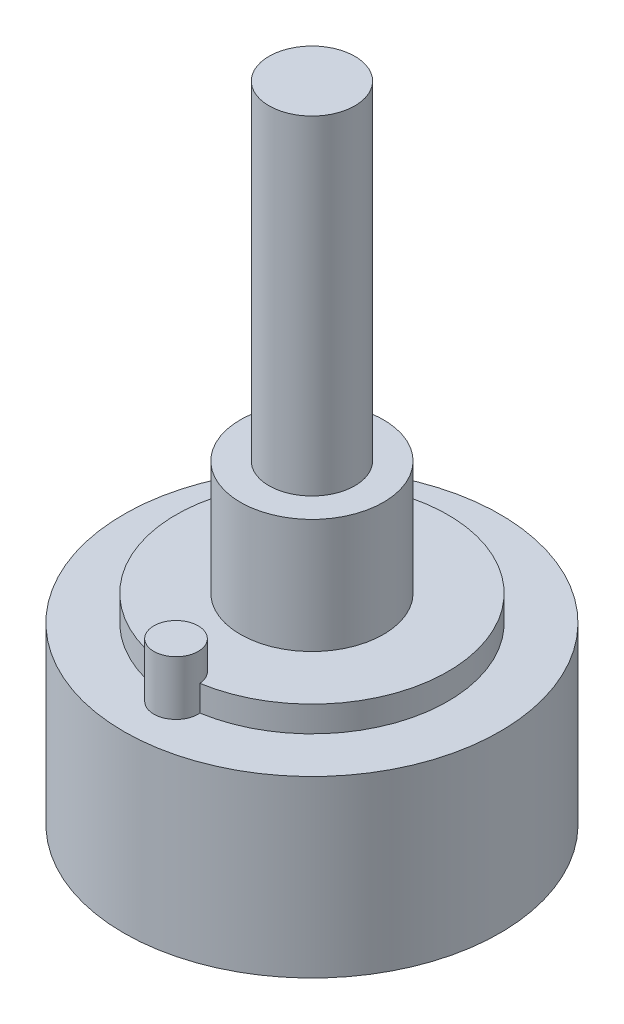
from build123d import *

# Parameters (mm, degrees)
SKETCH1_R           = 13.15
BOSS_EXTRUDE1_DEPTH = 12.2
SKETCH2_R           = 9.5
BOSS_EXTRUDE2_DEPTH = 1.8
SKETCH3_R           = 5
BOSS_EXTRUDE3_DEPTH = 8
SKETCH4_R           = 3
BOSS_EXTRUDE4_DEPTH = 23
SKETCH5_R           = 1.55
BOSS_EXTRUDE5_DEPTH = 3.8


with BuildPart() as part:
    # Sketch1 → Boss-Extrude1 (new body)
    with BuildSketch(Plane(origin=(0, 0, 0), x_dir=(1, 0, 0), z_dir=(0, 1, 0))):
        Circle(SKETCH1_R)
    extrude(amount=BOSS_EXTRUDE1_DEPTH)

    # Sketch2 → Boss-Extrude2 (add)
    with BuildSketch(Plane(origin=(0, 12.2, 0), x_dir=(1, 0, 0), z_dir=(0, 1, 0))):
        Circle(SKETCH2_R)
    extrude(amount=BOSS_EXTRUDE2_DEPTH)

    # Sketch3 → Boss-Extrude3 (add)
    with BuildSketch(Plane(origin=(0, 14, 0), x_dir=(1, 0, 0), z_dir=(0, 1, 0))):
        Circle(SKETCH3_R)
    extrude(amount=BOSS_EXTRUDE3_DEPTH)

    # Sketch4 → Boss-Extrude4 (add)
    with BuildSketch(Plane(origin=(0, 22, 0), x_dir=(1, 0, 0), z_dir=(0, 1, 0))):
        Circle(SKETCH4_R)
    extrude(amount=BOSS_EXTRUDE4_DEPTH)

    # Sketch5 → Boss-Extrude5 (add)
    with BuildSketch(Plane(origin=(0, 12.2, 0), x_dir=(1, 0, 0), z_dir=(0, 1, 0))):
        with Locations((0, -9.5)):
            Circle(SKETCH5_R)
    extrude(amount=BOSS_EXTRUDE5_DEPTH)


solid = part.part
